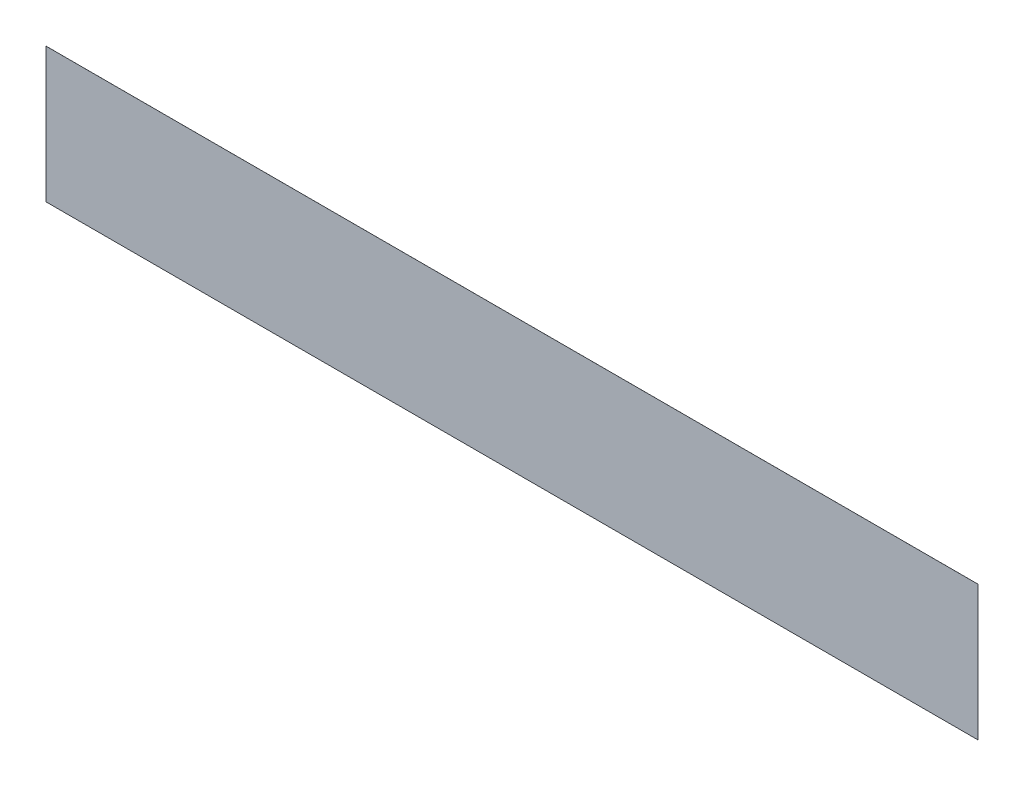
from build123d import *

# Parameters (mm, degrees)
CROQUIS1_W              = 38000
CROQUIS1_H              = 5500
SALIENTE_EXTRUIR1_DEPTH = 1


with BuildPart() as part:
    # Croquis1 → Saliente-Extruir1 (new body)
    with BuildSketch(Plane.XY):
        Rectangle(CROQUIS1_W, CROQUIS1_H)
    extrude(amount=SALIENTE_EXTRUIR1_DEPTH)


solid = part.part
